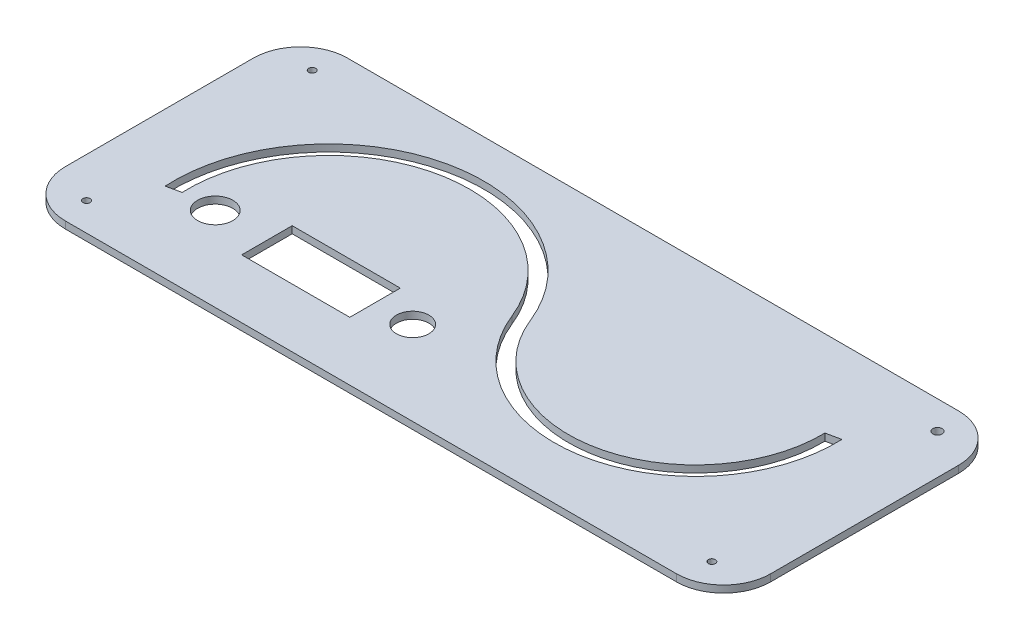
from build123d import *

# Parameters (mm, degrees)
SKETCH_2_W      = 300
SKETCH_2_H      = 120
SKETCH_2_R      = 1.5
SKETCH_2_R_2    = 2
SKETCH_2_R_3    = 6.9
SKETCH_2_R_4    = 7.5
SKETCH_2_W_2    = 46
SKETCH_2_H_2    = 21.5
EXTRUDE_2_DEPTH = 3
FILLET_1_R      = 20


with BuildPart() as part:
    # Эскиз2 → Бобышка-Вытянуть2 (new body)
    with BuildSketch(Plane(origin=(0, 0, 0), x_dir=(1, 0, 0), z_dir=(0, 1, 0))):
        with Locations((-150, 60)):
            Rectangle(SKETCH_2_W, SKETCH_2_H)
        with Locations((-283, 108)):
            Circle(SKETCH_2_R, mode=Mode.SUBTRACT)
        with Locations((-17, 108)):
            Circle(SKETCH_2_R_2, mode=Mode.SUBTRACT)
        with Locations((-17, 12)):
            Circle(SKETCH_2_R, mode=Mode.SUBTRACT)
        with Locations((-283, 12)):
            Circle(SKETCH_2_R, mode=Mode.SUBTRACT)
        with Locations((-168, 35.746485704)):
            Circle(SKETCH_2_R_3, mode=Mode.SUBTRACT)
        with Locations((-252, 35.746485704)):
            Circle(SKETCH_2_R_4, mode=Mode.SUBTRACT)
        with BuildLine():
            Line((-271.607074704, 34.057157396), (-265.660946054, 35.325664842))
            ThreePointArc((-265.660946054, 35.325664842), (-218.226909759, 96.396129604), (-150, 60))
            ThreePointArc((-150, 60), (-81.773090241, 23.603870396), (-34.339053946, 84.674335158))
            Line((-34.339053946, 84.674335158), (-40.302985362, 83.402029789))
            ThreePointArc((-40.302985362, 83.402029789), (-83.530907836, 29.366412701), (-144.429139855, 62.228344058))
            ThreePointArc((-144.429139855, 62.228344058), (-219.982275004, 102.154609074), (-271.607074704, 34.057157396))
        make_face(mode=Mode.SUBTRACT)
        with Locations((-207, 35.746485704)):
            Rectangle(SKETCH_2_W_2, SKETCH_2_H_2, mode=Mode.SUBTRACT)
    extrude(amount=EXTRUDE_2_DEPTH)

    # Скругление1
    fillet_1_edges = [part.edges().sort_by_distance(p)[0] for p in [
        (0, 1.5, 0),
        (-300, 1.5, 0),
        (-300, 1.5, -120),
        (0, 1.5, -120),
    ]]
    fillet(fillet_1_edges, radius=FILLET_1_R)


solid = part.part
